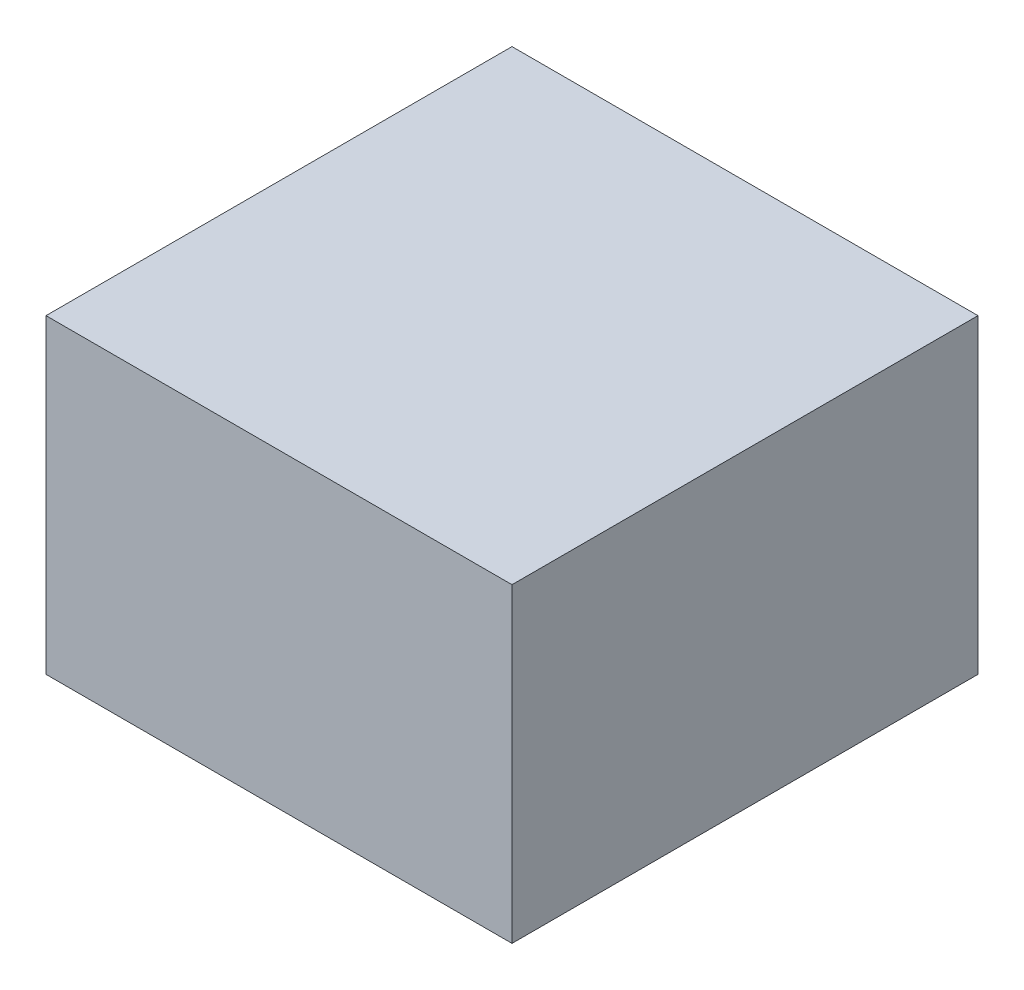
from build123d import *

# Parameters (mm, degrees)
SKETCH1_W      = 152.4
SKETCH1_H      = 152.4
EXTRUDE1_DEPTH = 50.8


with BuildPart() as part:
    # Sketch1 → Extrude1 (new body, symmetric)
    with BuildSketch(Plane(origin=(0, 0, 0), x_dir=(1, 0, 0), z_dir=(0, 1, 0))):
        Rectangle(SKETCH1_W, SKETCH1_H)
    extrude(amount=EXTRUDE1_DEPTH, both=True)


solid = part.part
